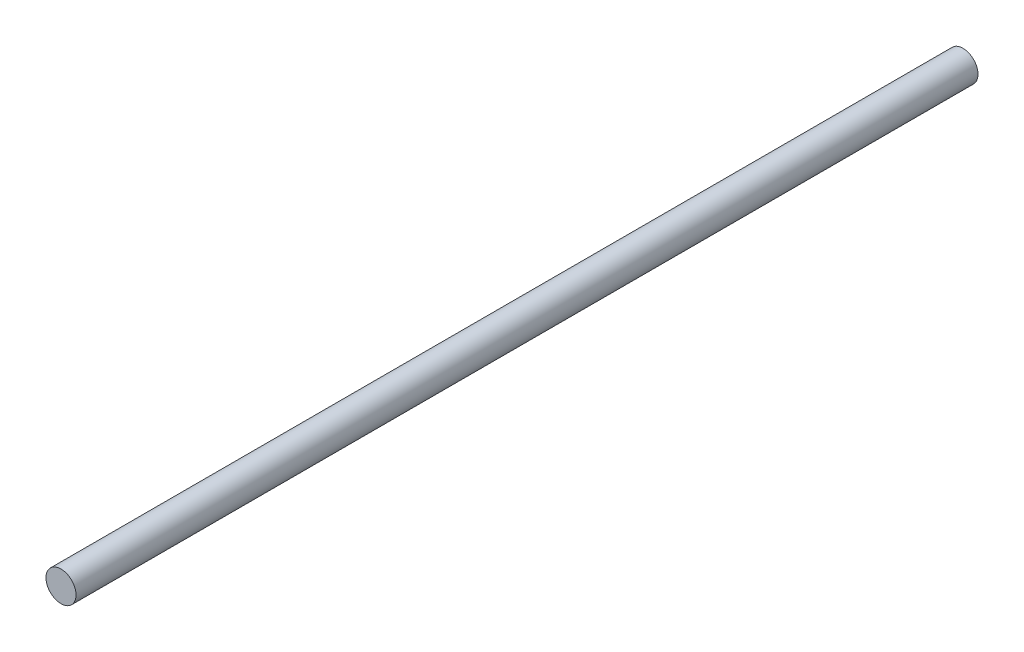
from build123d import *

# Parameters (mm, degrees)
SKETCH_1_R      = 5
EXTRUDE_1_DEPTH = 300


with BuildPart() as part:
    # 草图1 → 凸台-拉伸1 (new body)
    with BuildSketch(Plane.XY):
        Circle(SKETCH_1_R)
    extrude(amount=EXTRUDE_1_DEPTH)


solid = part.part
